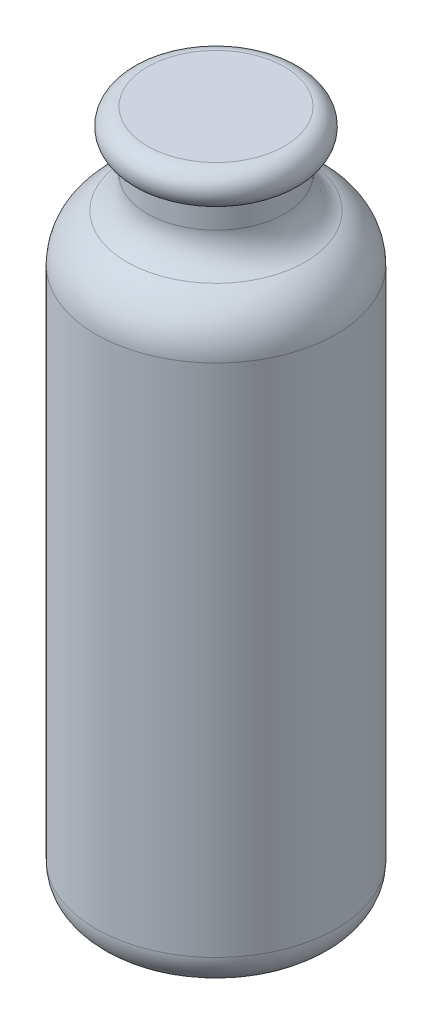
from build123d import *


with BuildPart() as part:
    # Sketch1 → Revolve2 (revolve)
    with BuildSketch(Plane.XY):
        with BuildLine():
            Line((-35, 10), (-35, 160))
            ThreePointArc((-35, 160), (-32.549900398, 168.215838363), (-26, 173.747727085))
            ThreePointArc((-26, 173.747727085), (-21.633399735, 177.4356529), (-20, 182.912878475))
            Line((-20, 182.912878475), (-20, 190))
            ThreePointArc((-20, 190), (-25, 195), (-20, 200))
            Line((-20, 200), (0, 200))
            Line((0, 200), (0, 199))
            Line((0, 199), (-20, 199))
            ThreePointArc((-20, 199), (-24, 195), (-20, 191))
            Line((-20, 191), (-19, 191))
            Line((-19, 191), (-19, 182.912878475))
            ThreePointArc((-19, 182.912878475), (-20.796739708, 176.887930342), (-25.6, 172.831211946))
            ThreePointArc((-25.6, 172.831211946), (-31.713240371, 167.668115805), (-34, 160))
            Line((-34, 160), (-34, 10))
            ThreePointArc((-34, 10), (-31.363961031, 3.636038969), (-25, 1))
            Line((-25, 1), (0, 1))
            Line((0, 1), (0, 0))
            Line((0, 0), (-25, 0))
            ThreePointArc((-25, 0), (-32.071067812, 2.928932188), (-35, 10))
        make_face()
    revolve(axis=Axis((0, 284.87669348, 0), (0, -1, 0)))


solid = part.part
